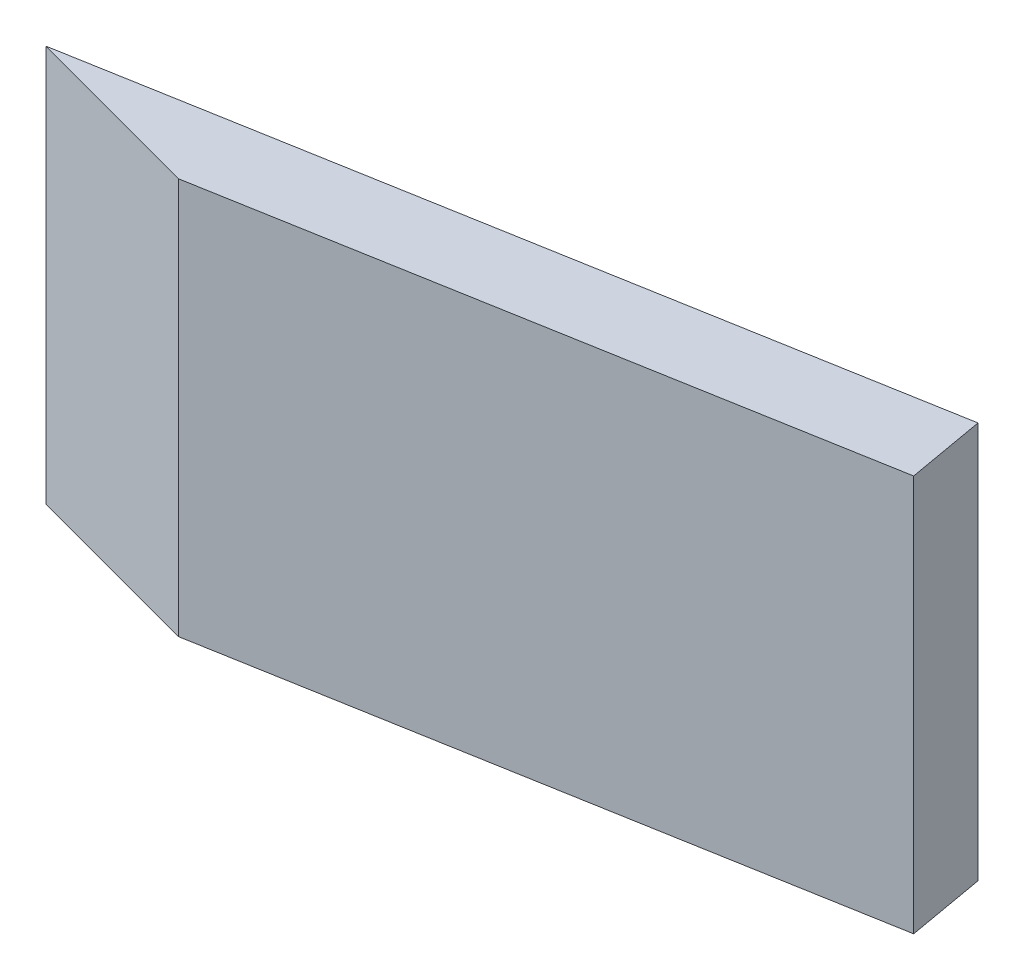
from build123d import *

# Parameters (mm, degrees)
BOSS_EXTRUDE1_DEPTH = 31.75


with BuildPart() as part:
    # Sketch1 → Boss-Extrude1 (new body)
    with BuildSketch(Plane(origin=(0, 0, 0), x_dir=(1, 0, 0), z_dir=(0, 1, 0))):
        Polygon((0, 0), (63.438970568, 11.186002139), (64.541636496, 4.932472908), (14.513402643, -3.888854518), align=None)
    extrude(amount=BOSS_EXTRUDE1_DEPTH)


solid = part.part
